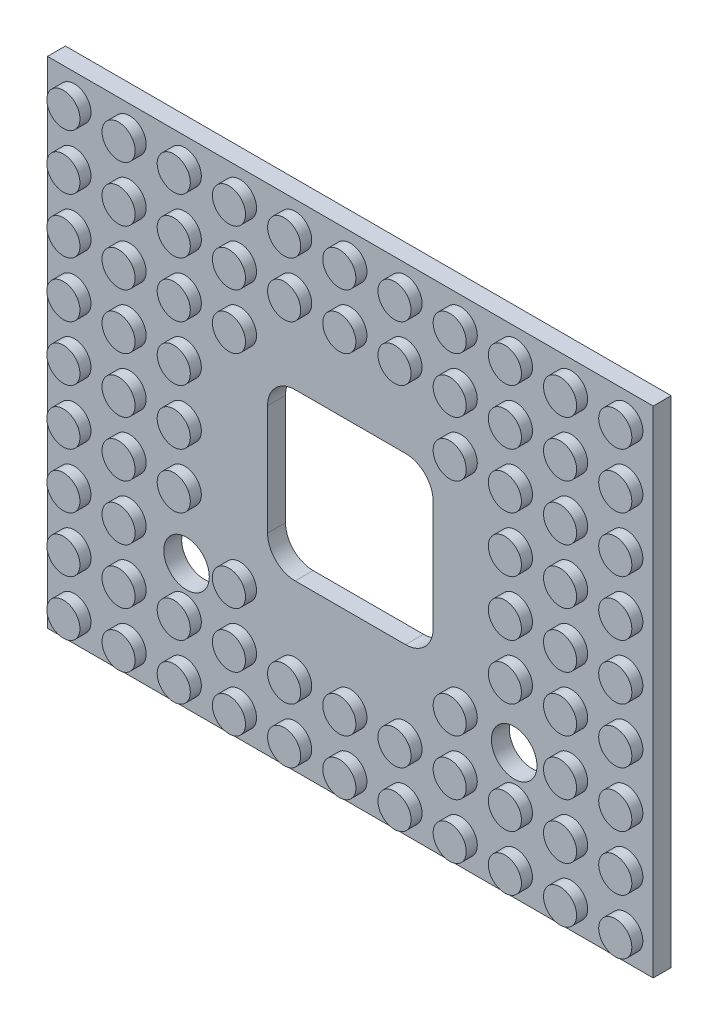
from build123d import *

# Parameters (mm, degrees)
SKETCH1_W            = 87.8
SKETCH1_H            = 71.8
BOSS_EXTRUDE1_DEPTH  = 2.6
CUT_EXTRUDE1_DEPTH   = 3.6
SKETCH4_R            = 3.3
CUT_EXTRUDE2_DEPTH   = 3.6
SKETCH3_R            = 2.4
BOSS_EXTRUDE2_DEPTH  = 1.6
LPATTERN1_COUNT      = 9
LPATTERN1_PITCH      = 8
LPATTERN1_COUNT_DIR2 = 11
LPATTERN1_PITCH_DIR2 = 8


with BuildPart() as part:
    # Sketch1 → Boss-Extrude1 (new body)
    with BuildSketch(Plane.XY):
        Rectangle(SKETCH1_W, SKETCH1_H)
    extrude(amount=BOSS_EXTRUDE1_DEPTH)

    # Sketch2 → Cut-Extrude1 (cut, through all)
    with BuildSketch(Plane.XY):
        with BuildLine():
            Line((-8, 12), (8, 12))
            ThreePointArc((8, 12), (10.828427125, 10.828427125), (12, 8))
            Line((12, 8), (12, -8))
            ThreePointArc((12, -8), (10.828427125, -10.828427125), (8, -12))
            Line((8, -12), (-8, -12))
            ThreePointArc((-8, -12), (-10.828427125, -10.828427125), (-12, -8))
            Line((-12, -8), (-12, 8))
            ThreePointArc((-12, 8), (-10.828427125, 10.828427125), (-8, 12))
        make_face()
    extrude(amount=CUT_EXTRUDE1_DEPTH, mode=Mode.SUBTRACT)

    # Sketch4 → Cut-Extrude2 (cut, through all)
    with BuildSketch(Plane.XY.offset(2.6)):
        with Locations((-23.75, -17.7)):
            Circle(SKETCH4_R)
    cut_extrude2 = extrude(amount=-CUT_EXTRUDE2_DEPTH, mode=Mode.SUBTRACT)

    # Mirror1: Cut-Extrude2 across plane
    add(cut_extrude2.mirror(Plane(origin=(0, 0, 0), x_dir=(0, 0, 1), z_dir=(1, 0, 0))), mode=Mode.SUBTRACT)

    # Sketch3 → Boss-Extrude2 (add)
    with BuildSketch(Plane.XY.offset(2.6)):
        with Locations((-40, -32)):
            Circle(SKETCH3_R)
    boss_extrude2 = extrude(amount=BOSS_EXTRUDE2_DEPTH)

    # LPattern1: Boss-Extrude2 9 × 11, 23 skipped
    with Locations(*[(j * LPATTERN1_PITCH_DIR2, i * LPATTERN1_PITCH, 0) for i in range(LPATTERN1_COUNT) for j in range(LPATTERN1_COUNT_DIR2) if (i, j) not in ((0, 0), (2, 2), (2, 4), (2, 5), (2, 6), (2, 8), (3, 3), (3, 4), (3, 5), (3, 6), (3, 7), (4, 3), (4, 4), (4, 5), (4, 6), (4, 7), (5, 3), (5, 4), (5, 5), (5, 6), (5, 7), (6, 4), (6, 5), (6, 6))]):
        add(boss_extrude2)


solid = part.part
